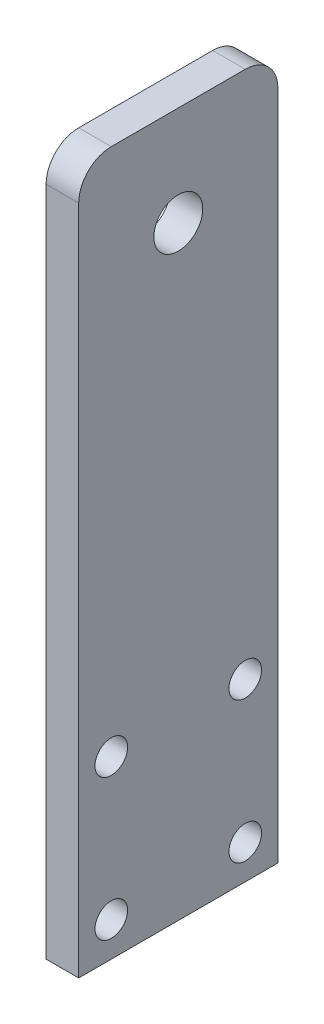
from build123d import *

# Parameters (mm, degrees)
SKETCH1_R           = 4.762500002
SKETCH1_W           = 38.8
SKETCH1_H           = 40.878125
SKETCH1_R_2         = 3.175
BOSS_EXTRUDE1_DEPTH = 6.35
FILLET1_R           = 6.35


with BuildPart() as part:
    # Sketch1 → Boss-Extrude1 (new body)
    with BuildSketch(Plane(origin=(0, 0, 0), x_dir=(0, 0, -1), z_dir=(1, 0, 0))):
        Polygon((19.4, 20.4390625), (-19.4, 20.4390625), (-19.4, 77.846455089), (-19.4, 116.646455089), (19.4, 116.646455089), (19.4, 77.846455095), align=None)
        with Locations((0, 97.246455089)):
            Circle(SKETCH1_R, mode=Mode.SUBTRACT)
        Rectangle(SKETCH1_W, SKETCH1_H)
        with Locations((13.05, -13.748956991)):
            Circle(SKETCH1_R_2, mode=Mode.SUBTRACT)
        with Locations((-13.05, -13.748956991)):
            Circle(SKETCH1_R_2, mode=Mode.SUBTRACT)
        with Locations((13.05, 13.748956991)):
            Circle(SKETCH1_R_2, mode=Mode.SUBTRACT)
        with Locations((-13.05, 13.748956991)):
            Circle(SKETCH1_R_2, mode=Mode.SUBTRACT)
    extrude(amount=BOSS_EXTRUDE1_DEPTH)

    # Fillet1
    fillet1_edges = [part.edges().sort_by_distance(p)[0] for p in [
        (3.175, 116.646455089, 19.4),
        (3.175, 116.646455089, -19.4),
    ]]
    fillet(fillet1_edges, radius=FILLET1_R)


solid = part.part
